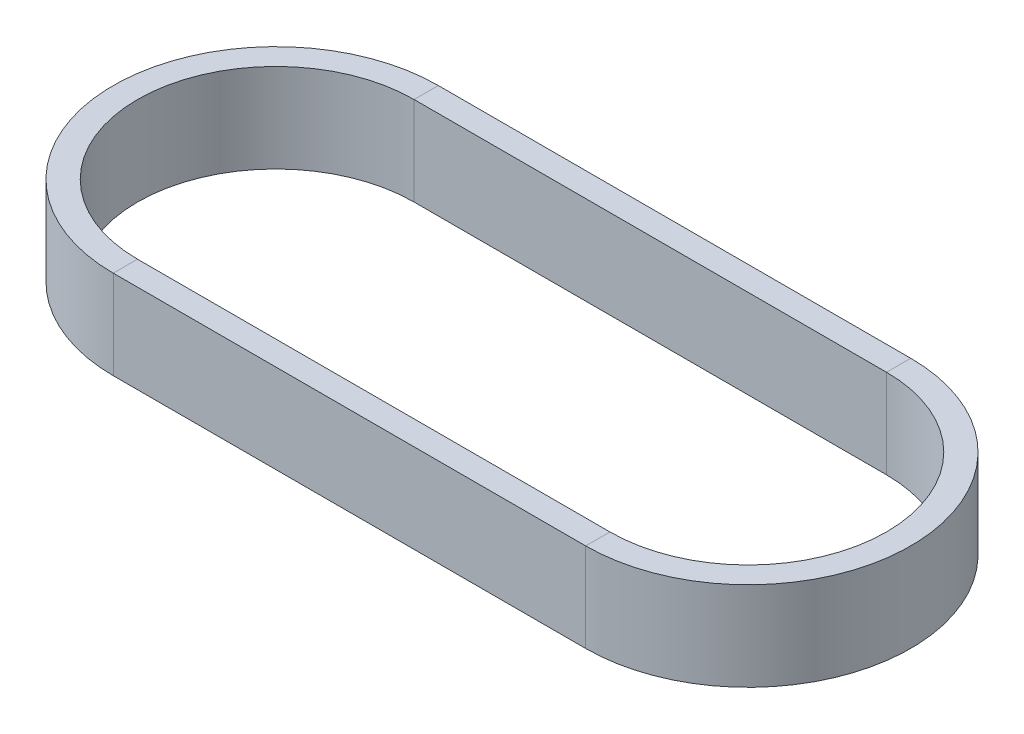
from build123d import *

# Parameters (mm, degrees)
SKETCH2_W = 6
SKETCH2_H = 22


with BuildPart() as part:
    # Sweep1: sweep along a path in Sketch1
    with BuildLine(Plane(origin=(0, 0, 0), x_dir=(1, 0, 0), z_dir=(0, 1, 0))) as sweep1_path:
        Line((0, -37.2489), (-117.00557942, -37.2489))
        ThreePointArc((-117.00557942, -37.2489), (-154.25447942, 0), (-117.00557942, 37.2489))
        Line((-117.00557942, 37.2489), (0, 37.2489))
        ThreePointArc((0, 37.2489), (37.2489, 0), (0, -37.2489))
    # Sketch2 → Sweep1 (sweep)
    with BuildSketch(Plane(origin=(-117.00557942, 0, 37.2489), x_dir=(0, 0, 1), z_dir=(-1, 0, 0))):
        Rectangle(SKETCH2_W, SKETCH2_H)
    sweep(path=sweep1_path.line)


solid = part.part
